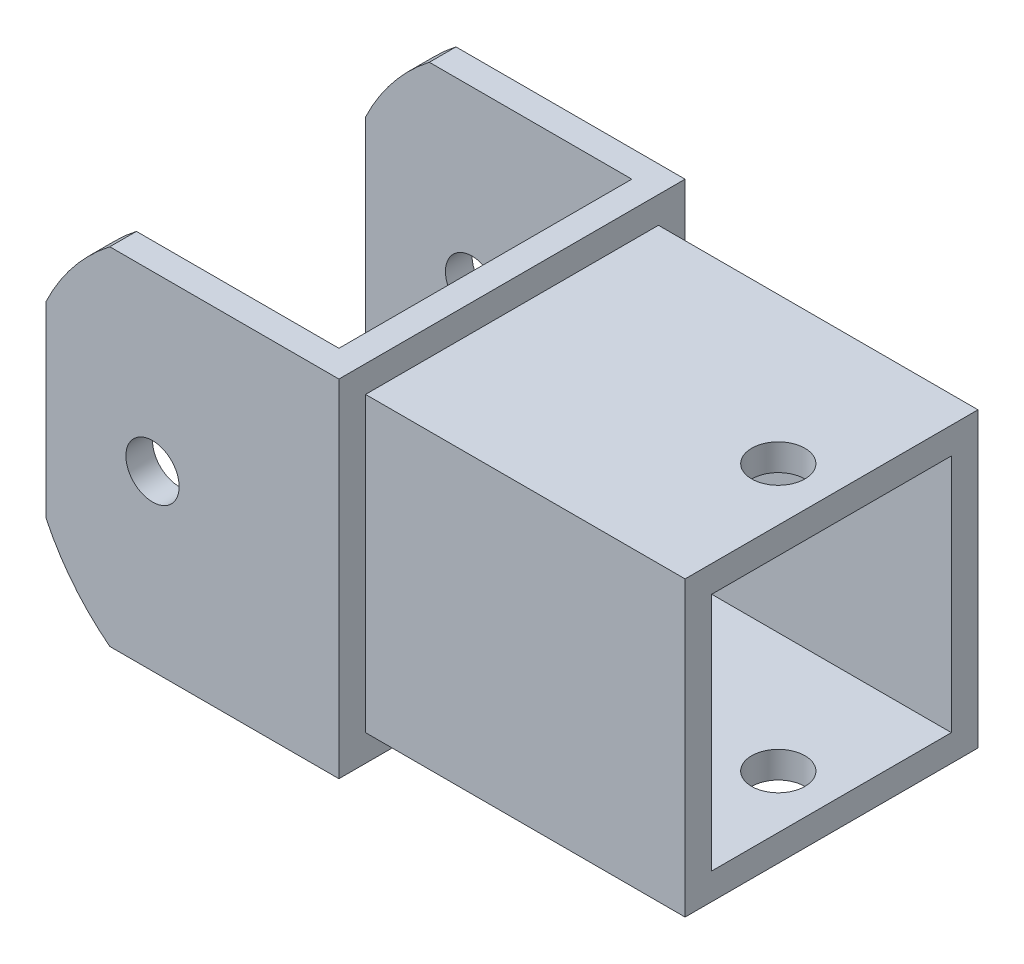
from build123d import *

# Parameters (mm, degrees)
BOSS_EXTRUDE1_DEPTH     = 82.55
SKETCH4_W               = 139.7
SKETCH4_H               = 139.7
SKETCH4_W_2             = 114.3
SKETCH4_H_2             = 114.3
BOSS_EXTRUDE2_DEPTH     = 152.4
SKETCH5_R               = 12.7
CUT_EXTRUDE1_DEPTH      = 1
CUT_EXTRUDE1_DEPTH_BACK = 166.1
SKETCH6_R               = 12.7
CUT_EXTRUDE2_DEPTH      = 13.7
CUT_EXTRUDE2_DEPTH_BACK = 153.4
CUT_EXTRUDE4_DEPTH      = 1
CUT_EXTRUDE4_DEPTH_BACK = 166.1
BODY_MOVE_COPY1_ANGLE   = 90
BODY_MOVE_COPY2_ANGLE   = 90


with BuildPart() as part:
    # Sketch2 → Boss-Extrude1 (new body, symmetric)
    with BuildSketch(Plane(origin=(0, 0, 0), x_dir=(1, 0, 0), z_dir=(0, 1, 0))):
        Polygon((-50.8, 38.1), (76.2, 38.1), (76.2, -101.6), (-50.8, -101.6), (-50.8, -114.3), (88.9, -114.3), (88.9, 50.8), (-50.8, 50.8), align=None)
    extrude(amount=BOSS_EXTRUDE1_DEPTH, both=True)

    # Sketch4 → Boss-Extrude2 (add)
    with BuildSketch(Plane(origin=(88.9, 0, 0), x_dir=(0, 0, -1), z_dir=(1, 0, 0))):
        with Locations((-31.75, 0)):
            Rectangle(SKETCH4_W, SKETCH4_H)
        with Locations((-31.75, 0)):
            Rectangle(SKETCH4_W_2, SKETCH4_H_2, mode=Mode.SUBTRACT)
    extrude(amount=BOSS_EXTRUDE2_DEPTH)

    # Sketch5 → Cut-Extrude1 (cut, two sides)
    with BuildSketch(Plane.XY.offset(114.3)) as cut_extrude1_sk:
        Circle(SKETCH5_R)
    extrude(amount=CUT_EXTRUDE1_DEPTH, mode=Mode.SUBTRACT)
    extrude(cut_extrude1_sk.sketch, amount=-CUT_EXTRUDE1_DEPTH_BACK, mode=Mode.SUBTRACT)

    # Sketch6 → Cut-Extrude2 (cut, two sides)
    with BuildSketch(Plane(origin=(0, 69.85, 0), x_dir=(1, 0, 0), z_dir=(0, 1, 0))) as cut_extrude2_sk:
        with Locations((215.9, -31.75)):
            Circle(SKETCH6_R)
    extrude(amount=CUT_EXTRUDE2_DEPTH, mode=Mode.SUBTRACT)
    extrude(cut_extrude2_sk.sketch, amount=-CUT_EXTRUDE2_DEPTH_BACK, mode=Mode.SUBTRACT)

    # Sketch7 → Cut-Extrude4 (cut, two sides)
    with BuildSketch(Plane.XY.offset(114.3)) as cut_extrude4_sk:
        with BuildLine():
            Line((-20.374273833, 82.55), (-68.429055494, 82.55))
            Line((-68.429055494, 82.55), (-68.429055494, -82.55))
            Line((-68.429055494, -82.55), (-20.374273833, -82.55))
            ThreePointArc((-20.374273833, -82.55), (-60.854450977, 0), (-20.374273833, 82.55))
        make_face()
    extrude(amount=CUT_EXTRUDE4_DEPTH, mode=Mode.SUBTRACT)
    extrude(cut_extrude4_sk.sketch, amount=-CUT_EXTRUDE4_DEPTH_BACK, mode=Mode.SUBTRACT)


with BuildPart() as part_1:
    # Body-Move/Copy1: moved
    add(part.part.rotate(Axis((0, 0, 31.75025), (1, 0, 0)), BODY_MOVE_COPY1_ANGLE))


with BuildPart() as part_2:
    # Body-Move/Copy2: moved
    add(part_1.part.rotate(Axis((0, 0, 31.75025), (-1, 0, 0)), BODY_MOVE_COPY2_ANGLE))


solid = part_2.part
